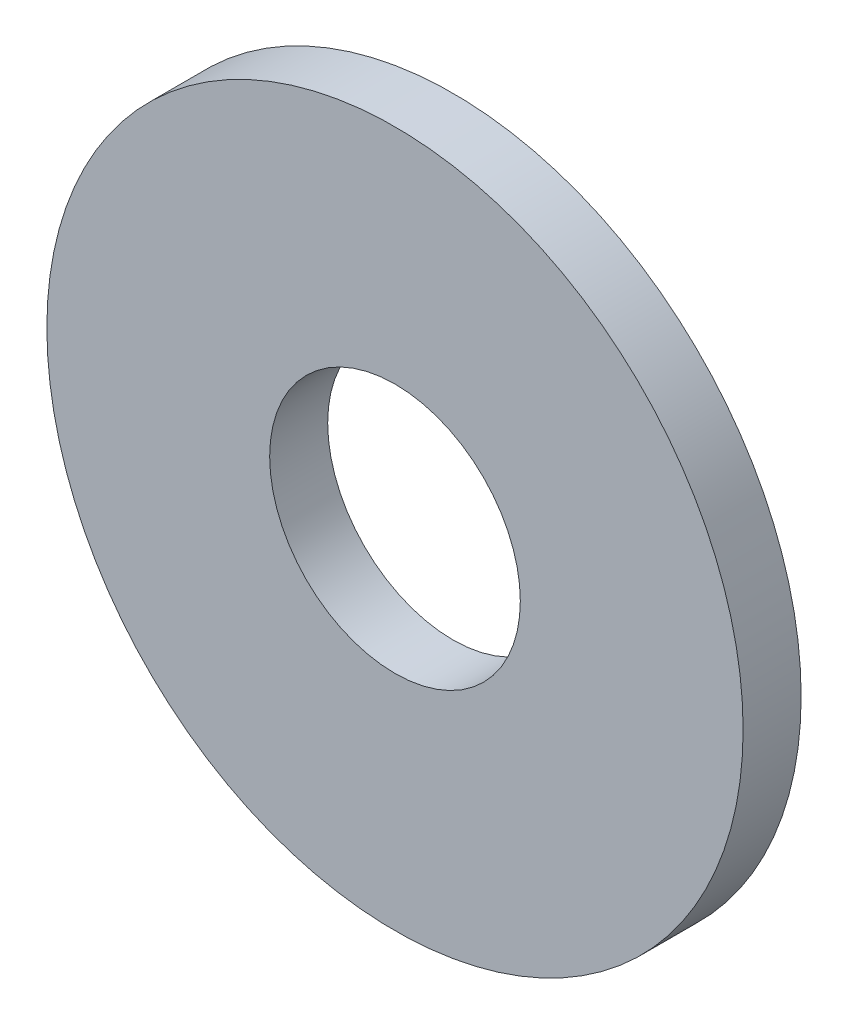
from build123d import *

# Parameters (mm, degrees)
SKETCH1_R           = 9.525
SKETCH1_R_2         = 3.429
BOSS_EXTRUDE1_DEPTH = 1.5875


with BuildPart() as part:
    # Sketch1 → Boss-Extrude1 (new body)
    with BuildSketch(Plane.XY):
        Circle(SKETCH1_R)
        Circle(SKETCH1_R_2, mode=Mode.SUBTRACT)
    extrude(amount=BOSS_EXTRUDE1_DEPTH)


solid = part.part
